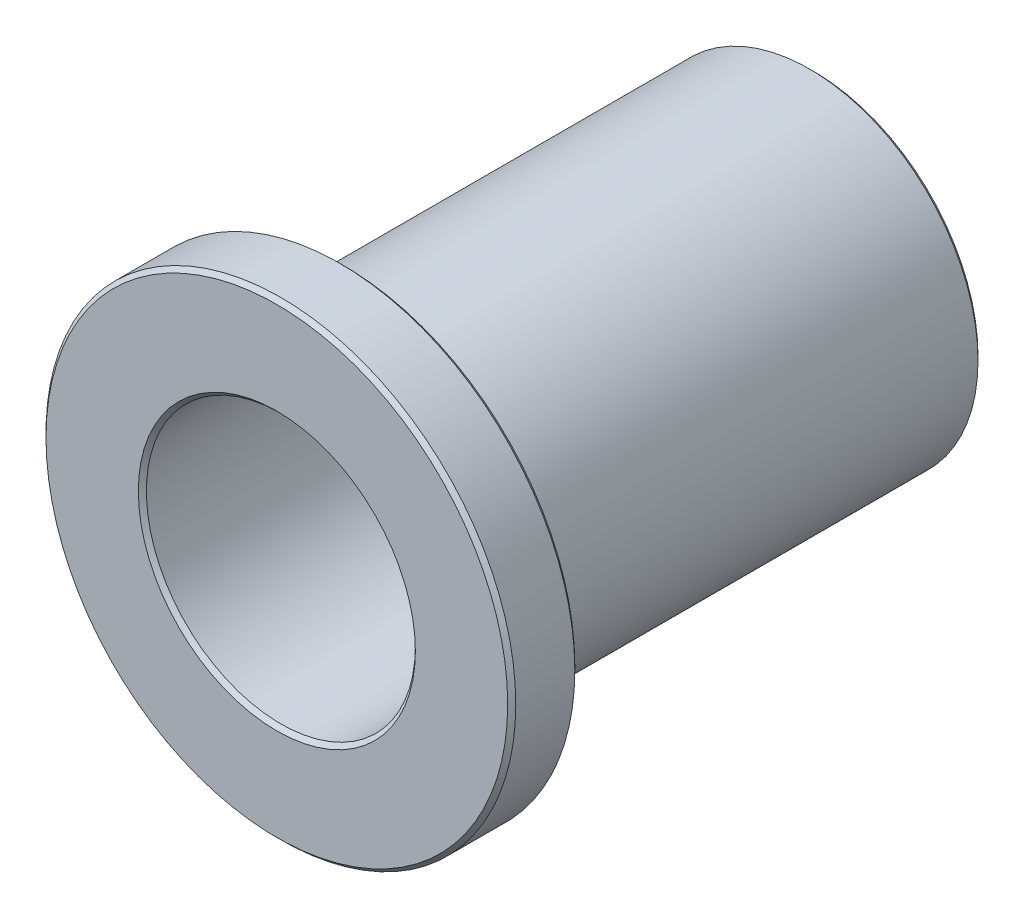
from build123d import *

# Parameters (mm, degrees)
BOSS_EXTRUDE1_START = 12.7
SKETCH3_R           = 11.1125
SKETCH3_R_2         = 6.3627
BOSS_EXTRUDE1_DEPTH = 3.175
BOSS_EXTRUDE2_START = 9.525
SKETCH4_R           = 7.9629
SKETCH4_R_2         = 6.3627
BOSS_EXTRUDE2_DEPTH = 22.225
CHAMFER1_SIZE       = 0.190881


with BuildPart() as part:
    # Sketch3 → Boss-Extrude1 (new body)
    with BuildSketch(Plane.XY.offset(BOSS_EXTRUDE1_START)):
        Circle(SKETCH3_R)
        Circle(SKETCH3_R_2, mode=Mode.SUBTRACT)
    extrude(amount=-BOSS_EXTRUDE1_DEPTH)

    # Sketch4 → Boss-Extrude2 (add)
    with BuildSketch(Plane.XY.offset(BOSS_EXTRUDE2_START)):
        Circle(SKETCH4_R)
        Circle(SKETCH4_R_2, mode=Mode.SUBTRACT)
    extrude(amount=-BOSS_EXTRUDE2_DEPTH)

    # Chamfer1
    chamfer1_edges = [part.edges().sort_by_distance(p)[0] for p in [
        (-6.3627, 0, -12.7),
        (-7.9629, 0, 9.525),
        (-11.1125, 0, 12.7),
        (-11.1125, 0, 9.525),
        (-6.3627, 0, 12.7),
        (-7.9629, 0, -12.7),
    ]]
    chamfer(chamfer1_edges, length=CHAMFER1_SIZE)


solid = part.part
